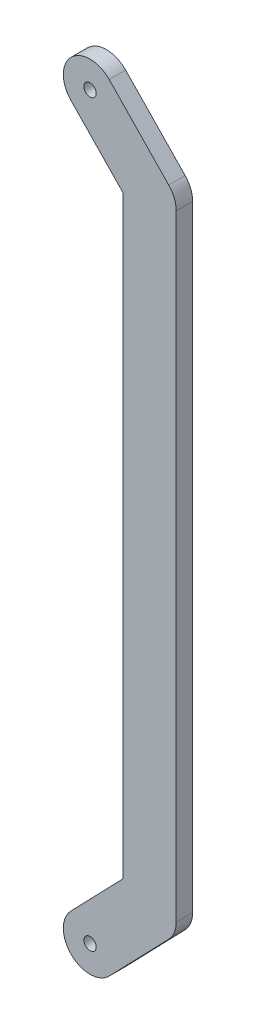
from build123d import *

# Parameters (mm, degrees)
EXTRUDE_1_DEPTH        = 4
HOLE_WIZARD_M3_1_D     = 3
HOLE_WIZARD_M3_1_DEPTH = 10
HOLE_WIZARD_M3_1_TIP   = 0.901290929


with BuildPart() as part:
    # 草图1 → 凸台-拉伸1 (new body)
    with BuildSketch(Plane.XY):
        with BuildLine():
            Line((7.985331622, 162.373829532), (7.985331622, 17.626170468))
            Line((7.985331622, 17.626170468), (9.80962292, 19.515279408))
            ThreePointArc((9.80962292, 19.515279408), (16.920274479, 21.026695055), (20.985331622, 15))
            Line((20.985331622, 15), (20.985331622, 165))
            ThreePointArc((20.985331622, 165), (16.920274479, 158.973304945), (9.80962292, 160.484720592))
            Line((9.80962292, 160.484720592), (7.985331622, 162.373829532))
        make_face()
        with BuildLine():
            Line((-4.675708702, 175.484720592), (7.985331622, 162.373829532))
            Line((7.985331622, 162.373829532), (7.985331622, 165))
            ThreePointArc((7.985331622, 165), (12.050388765, 171.026695055), (19.161040324, 169.515279408))
            Line((19.161040324, 169.515279408), (4.675708702, 184.515279408))
            ThreePointArc((4.675708702, 184.515279408), (-4.515279408, 184.675708702), (-4.675708702, 175.484720592))
        make_face()
        with BuildLine():
            Line((7.985331622, 165), (7.985331622, 162.373829532))
            Line((7.985331622, 162.373829532), (9.80962292, 160.484720592))
            ThreePointArc((9.80962292, 160.484720592), (16.920274479, 158.973304945), (20.985331622, 165))
            ThreePointArc((20.985331622, 165), (20.512026677, 167.434942857), (19.161040324, 169.515279408))
            ThreePointArc((19.161040324, 169.515279408), (12.050388765, 171.026695055), (7.985331622, 165))
        make_face()
        with BuildLine():
            Line((9.80962292, 19.515279408), (7.985331622, 17.626170468))
            Line((7.985331622, 17.626170468), (7.985331622, 15))
            ThreePointArc((7.985331622, 15), (12.050388765, 8.973304945), (19.161040324, 10.484720592))
            ThreePointArc((19.161040324, 10.484720592), (20.512026677, 12.565057143), (20.985331622, 15))
            ThreePointArc((20.985331622, 15), (16.920274479, 21.026695055), (9.80962292, 19.515279408))
        make_face()
        with BuildLine():
            Line((7.985331622, 17.626170468), (-4.675708702, 4.515279408))
            ThreePointArc((-4.675708702, 4.515279408), (-4.515279408, -4.675708702), (4.675708702, -4.515279408))
            Line((4.675708702, -4.515279408), (19.161040324, 10.484720592))
            ThreePointArc((19.161040324, 10.484720592), (12.050388765, 8.973304945), (7.985331622, 15))
            Line((7.985331622, 15), (7.985331622, 17.626170468))
        make_face()
    extrude(amount=EXTRUDE_1_DEPTH)

    # M3 螺纹孔1
    with Locations(Plane.XY.offset(4)):
        with Locations((0, 0), (0, 180)):
            Hole(HOLE_WIZARD_M3_1_D / 2, depth=HOLE_WIZARD_M3_1_DEPTH)
            with Locations((0, 0, -(HOLE_WIZARD_M3_1_DEPTH + HOLE_WIZARD_M3_1_TIP / 2))):  # 118° drill point
                Cone(0, HOLE_WIZARD_M3_1_D / 2, HOLE_WIZARD_M3_1_TIP, mode=Mode.SUBTRACT)


solid = part.part
